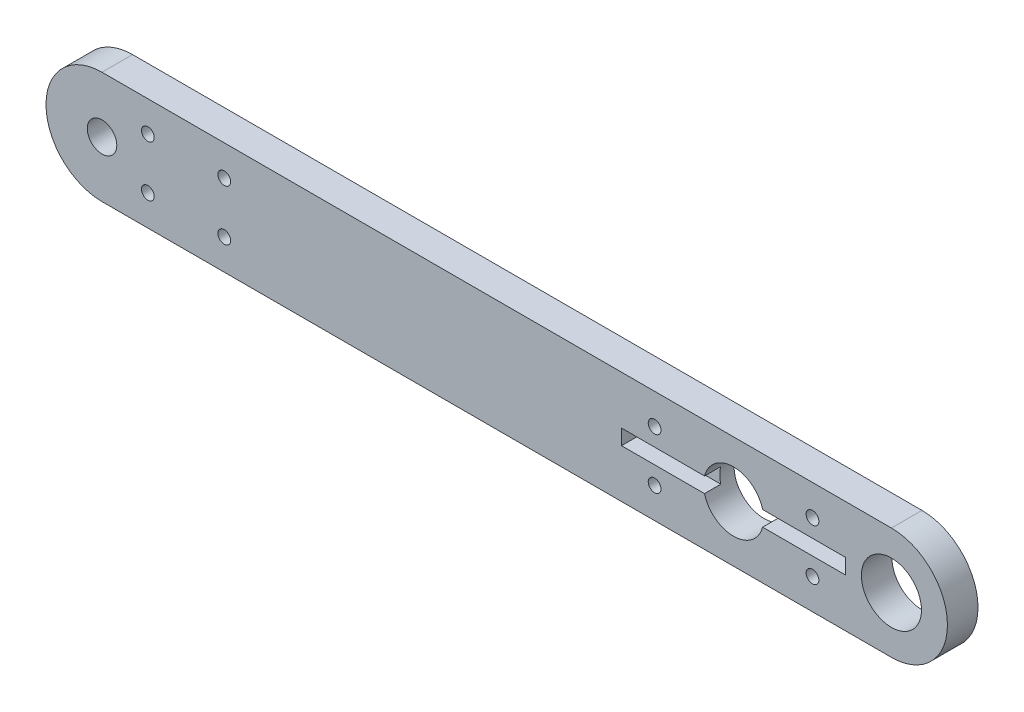
from build123d import *

# Parameters (mm, degrees)
SKETCH1_R               = 1.45
SKETCH1_R_2             = 2.95
BOSS_EXTRUDE1_DEPTH     = 3
TROU_TARAUD_M1_61_D     = 1.25
ESQUISSE3_W             = 22
ESQUISSE3_H             = 1.5
ENL_V_MAT_EXTRU_1_DEPTH = 1.6


with BuildPart() as part:
    # Sketch1 → Boss-Extrude1 (new body)
    with BuildSketch(Plane.XY):
        with BuildLine():
            Line((15.5, 5.5), (-62, 5.5))
            ThreePointArc((-62, 5.5), (-67.5, 0), (-62, -5.5))
            Line((-62, -5.5), (15.5, -5.5))
            ThreePointArc((15.5, -5.5), (21, 0), (15.5, 5.5))
        make_face()
        with Locations((-62, 0)):
            Circle(SKETCH1_R, mode=Mode.SUBTRACT)
        Circle(SKETCH1_R_2, mode=Mode.SUBTRACT)
        with Locations((15.5, 0)):
            Circle(SKETCH1_R_2, mode=Mode.SUBTRACT)
    extrude(amount=BOSS_EXTRUDE1_DEPTH)

    # Trou taraudé M1.61 (through all)
    with Locations(Plane.XY.offset(3)):
        with Locations((7.75, 2.5), (-7.75, 2.5), (-57.5, 2.5), (-50, 2.5)):
            trou_taraud_m1_61 = Hole(TROU_TARAUD_M1_61_D / 2)

    # Mirror1: Trou taraudé M1.61 across plane
    add(trou_taraud_m1_61.mirror(Plane.ZX), mode=Mode.SUBTRACT)

    # Esquisse3 → Enlèv. mat.-Extru.1 (cut)
    with BuildSketch(Plane.XY.offset(3)):
        Rectangle(ESQUISSE3_W, ESQUISSE3_H)
    extrude(amount=-ENL_V_MAT_EXTRU_1_DEPTH, mode=Mode.SUBTRACT)


solid = part.part
